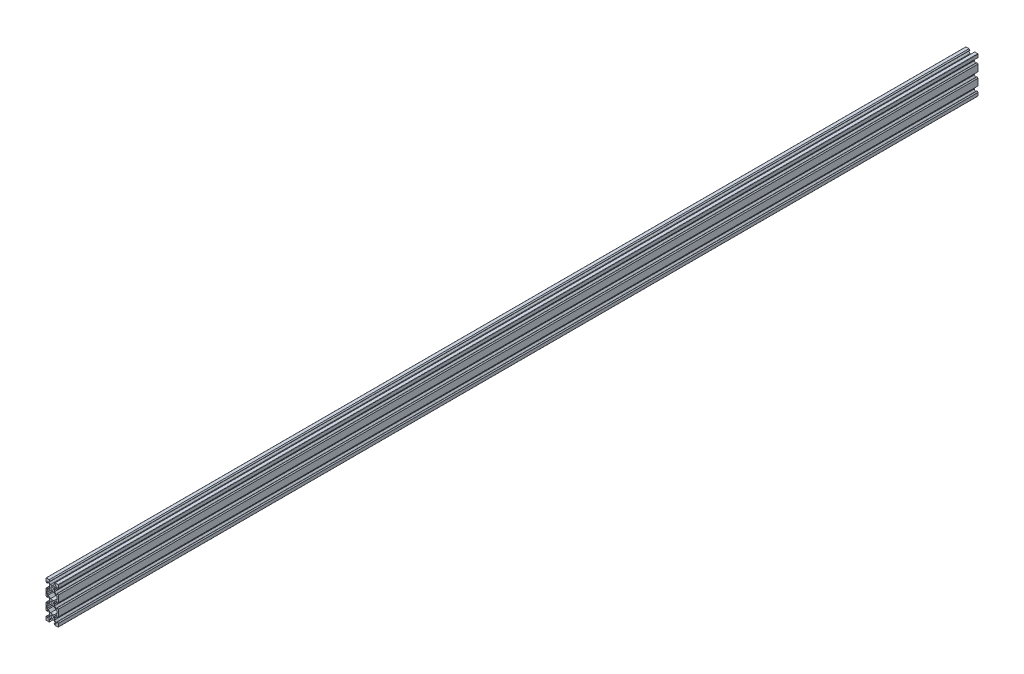
from build123d import *

# Parameters (mm, degrees)
SKETCH1_R           = 2.1
BOSS_EXTRUDE1_DEPTH = 1500


with BuildPart() as part:
    # Sketch1 → Boss-Extrude1 (new body)
    with BuildSketch(Plane.XY):
        with BuildLine():
            Line((4.58, -30), (9.5, -30))
            ThreePointArc((9.5, -30), (9.853553391, -29.853553391), (10, -29.5))
            Line((10, -29.5), (10, -24.58))
            Line((10, -24.58), (8.545, -23.125))
            Line((8.545, -23.125), (8.2, -23.125))
            Line((8.2, -23.125), (8.2, -25.5))
            Line((8.2, -25.5), (6.560660172, -25.5))
            Line((6.560660172, -25.5), (3.9, -22.839339828))
            Line((3.9, -22.839339828), (3.9, -20.21))
            Line((3.9, -20.21), (3.69, -20))
            Line((3.69, -20), (3.9, -19.79))
            Line((3.9, -19.79), (3.9, -17.160660172))
            Line((3.9, -17.160660172), (6.560660172, -14.5))
            Line((6.560660172, -14.5), (8.2, -14.5))
            Line((8.2, -14.5), (8.2, -16.875))
            Line((8.2, -16.875), (8.545, -16.875))
            Line((8.545, -16.875), (10, -15.42))
            Line((10, -15.42), (10, -4.58))
            Line((10, -4.58), (8.545, -3.125))
            Line((8.545, -3.125), (8.2, -3.125))
            Line((8.2, -3.125), (8.2, -5.5))
            Line((8.2, -5.5), (6.560660172, -5.5))
            Line((6.560660172, -5.5), (3.9, -2.839339828))
            Line((3.9, -2.839339828), (3.9, -0.21))
            Line((3.9, -0.21), (3.69, 0))
            Line((3.69, 0), (3.9, 0.21))
            Line((3.9, 0.21), (3.9, 2.839339828))
            Line((3.9, 2.839339828), (6.560660172, 5.5))
            Line((6.560660172, 5.5), (8.2, 5.5))
            Line((8.2, 5.5), (8.2, 3.125))
            Line((8.2, 3.125), (8.545, 3.125))
            Line((8.545, 3.125), (10, 4.58))
            Line((10, 4.58), (10, 15.42))
            Line((10, 15.42), (8.545, 16.875))
            Line((8.545, 16.875), (8.2, 16.875))
            Line((8.2, 16.875), (8.2, 14.5))
            Line((8.2, 14.5), (6.560660172, 14.5))
            Line((6.560660172, 14.5), (3.9, 17.160660172))
            Line((3.9, 17.160660172), (3.9, 19.79))
            Line((3.9, 19.79), (3.69, 20))
            Line((3.69, 20), (3.9, 20.21))
            Line((3.9, 20.21), (3.9, 22.839339828))
            Line((3.9, 22.839339828), (6.560660172, 25.5))
            Line((6.560660172, 25.5), (8.2, 25.5))
            Line((8.2, 25.5), (8.2, 23.125))
            Line((8.2, 23.125), (8.545, 23.125))
            Line((8.545, 23.125), (10, 24.58))
            Line((10, 24.58), (10, 29.5))
            ThreePointArc((10, 29.5), (9.853553391, 29.853553391), (9.5, 30))
            Line((9.5, 30), (4.58, 30))
            Line((4.58, 30), (3.125, 28.545))
            Line((3.125, 28.545), (3.125, 28.2))
            Line((3.125, 28.2), (5.5, 28.2))
            Line((5.5, 28.2), (5.5, 26.560660172))
            Line((5.5, 26.560660172), (2.839339828, 23.9))
            Line((2.839339828, 23.9), (0.21, 23.9))
            Line((0.21, 23.9), (0, 23.69))
            Line((0, 23.69), (-0.21, 23.9))
            Line((-0.21, 23.9), (-2.839339828, 23.9))
            Line((-2.839339828, 23.9), (-5.5, 26.560660172))
            Line((-5.5, 26.560660172), (-5.5, 28.2))
            Line((-5.5, 28.2), (-3.125, 28.2))
            Line((-3.125, 28.2), (-3.125, 28.545))
            Line((-3.125, 28.545), (-4.58, 30))
            Line((-4.58, 30), (-9.5, 30))
            ThreePointArc((-9.5, 30), (-9.853553391, 29.853553391), (-10, 29.5))
            Line((-10, 29.5), (-10, 24.58))
            Line((-10, 24.58), (-8.545, 23.125))
            Line((-8.545, 23.125), (-8.2, 23.125))
            Line((-8.2, 23.125), (-8.2, 25.5))
            Line((-8.2, 25.5), (-6.560660172, 25.5))
            Line((-6.560660172, 25.5), (-3.9, 22.839339828))
            Line((-3.9, 22.839339828), (-3.9, 20.21))
            Line((-3.9, 20.21), (-3.69, 20))
            Line((-3.69, 20), (-3.9, 19.79))
            Line((-3.9, 19.79), (-3.9, 17.160660172))
            Line((-3.9, 17.160660172), (-6.560660172, 14.5))
            Line((-6.560660172, 14.5), (-8.2, 14.5))
            Line((-8.2, 14.5), (-8.2, 16.875))
            Line((-8.2, 16.875), (-8.545, 16.875))
            Line((-8.545, 16.875), (-10, 15.42))
            Line((-10, 15.42), (-10, 4.58))
            Line((-10, 4.58), (-8.545, 3.125))
            Line((-8.545, 3.125), (-8.2, 3.125))
            Line((-8.2, 3.125), (-8.2, 5.5))
            Line((-8.2, 5.5), (-6.560660172, 5.5))
            Line((-6.560660172, 5.5), (-3.9, 2.839339828))
            Line((-3.9, 2.839339828), (-3.9, 0.21))
            Line((-3.9, 0.21), (-3.69, 0))
            Line((-3.69, 0), (-3.9, -0.21))
            Line((-3.9, -0.21), (-3.9, -2.839339828))
            Line((-3.9, -2.839339828), (-6.560660172, -5.5))
            Line((-6.560660172, -5.5), (-8.2, -5.5))
            Line((-8.2, -5.5), (-8.2, -3.125))
            Line((-8.2, -3.125), (-8.545, -3.125))
            Line((-8.545, -3.125), (-10, -4.58))
            Line((-10, -4.58), (-10, -15.42))
            Line((-10, -15.42), (-8.545, -16.875))
            Line((-8.545, -16.875), (-8.2, -16.875))
            Line((-8.2, -16.875), (-8.2, -14.5))
            Line((-8.2, -14.5), (-6.560660172, -14.5))
            Line((-6.560660172, -14.5), (-3.9, -17.160660172))
            Line((-3.9, -17.160660172), (-3.9, -19.79))
            Line((-3.9, -19.79), (-3.69, -20))
            Line((-3.69, -20), (-3.9, -20.21))
            Line((-3.9, -20.21), (-3.9, -22.839339828))
            Line((-3.9, -22.839339828), (-6.560660172, -25.5))
            Line((-6.560660172, -25.5), (-8.2, -25.5))
            Line((-8.2, -25.5), (-8.2, -23.125))
            Line((-8.2, -23.125), (-8.545, -23.125))
            Line((-8.545, -23.125), (-10, -24.58))
            Line((-10, -24.58), (-10, -29.5))
            ThreePointArc((-10, -29.5), (-9.853553391, -29.853553391), (-9.5, -30))
            Line((-9.5, -30), (-4.58, -30))
            Line((-4.58, -30), (-3.125, -28.545))
            Line((-3.125, -28.545), (-3.125, -28.2))
            Line((-3.125, -28.2), (-5.5, -28.2))
            Line((-5.5, -28.2), (-5.5, -26.560660172))
            Line((-5.5, -26.560660172), (-2.839339828, -23.9))
            Line((-2.839339828, -23.9), (-0.21, -23.9))
            Line((-0.21, -23.9), (0, -23.69))
            Line((0, -23.69), (0.21, -23.9))
            Line((0.21, -23.9), (2.839339828, -23.9))
            Line((2.839339828, -23.9), (5.5, -26.560660172))
            Line((5.5, -26.560660172), (5.5, -28.2))
            Line((5.5, -28.2), (3.125, -28.2))
            Line((3.125, -28.2), (3.125, -28.545))
            Line((3.125, -28.545), (4.58, -30))
        make_face()
        with Locations((0, -20)):
            Circle(SKETCH1_R, mode=Mode.SUBTRACT)
        Polygon((-6.239339828, -12.7), (-8.2, -12.7), (-8.2, -7.3), (-6.239339828, -7.3), (-2.839339828, -3.9), (2.839339828, -3.9), (6.239339828, -7.3), (8.2, -7.3), (8.2, -12.7), (6.239339828, -12.7), (2.839339828, -16.1), (-2.839339828, -16.1), align=None, mode=Mode.SUBTRACT)
        Polygon((-6.239339828, 7.3), (-8.2, 7.3), (-8.2, 12.7), (-6.239339828, 12.7), (-2.839339828, 16.1), (2.839339828, 16.1), (6.239339828, 12.7), (8.2, 12.7), (8.2, 7.3), (6.239339828, 7.3), (2.839339828, 3.9), (-2.839339828, 3.9), align=None, mode=Mode.SUBTRACT)
        with Locations((0, 20)):
            Circle(SKETCH1_R, mode=Mode.SUBTRACT)
        Circle(SKETCH1_R, mode=Mode.SUBTRACT)
    extrude(amount=BOSS_EXTRUDE1_DEPTH)


solid = part.part
